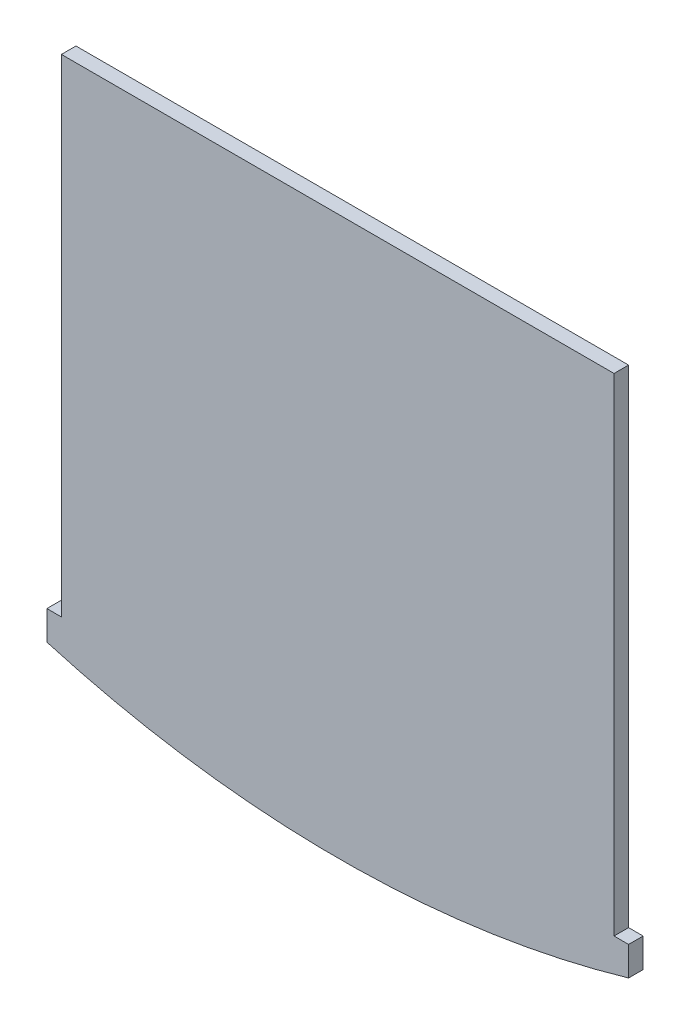
from build123d import *

# Parameters (mm, degrees)
BOSS_EXTRUDE1_DEPTH = 2


with BuildPart() as part:
    # Sketch2 → Boss-Extrude1 (new body)
    with BuildSketch(Plane.XY):
        with BuildLine():
            Line((38, 0), (-38, 0))
            Line((-38, 0), (-38, -67))
            Line((-38, -67), (-40, -67))
            Line((-40, -67), (-40, -71))
            ThreePointArc((-40, -71), (0, -76.708339656), (40, -71))
            Line((40, -71), (40, -67))
            Line((40, -67), (38, -67))
            Line((38, -67), (38, 0))
        make_face()
    extrude(amount=BOSS_EXTRUDE1_DEPTH)


solid = part.part
